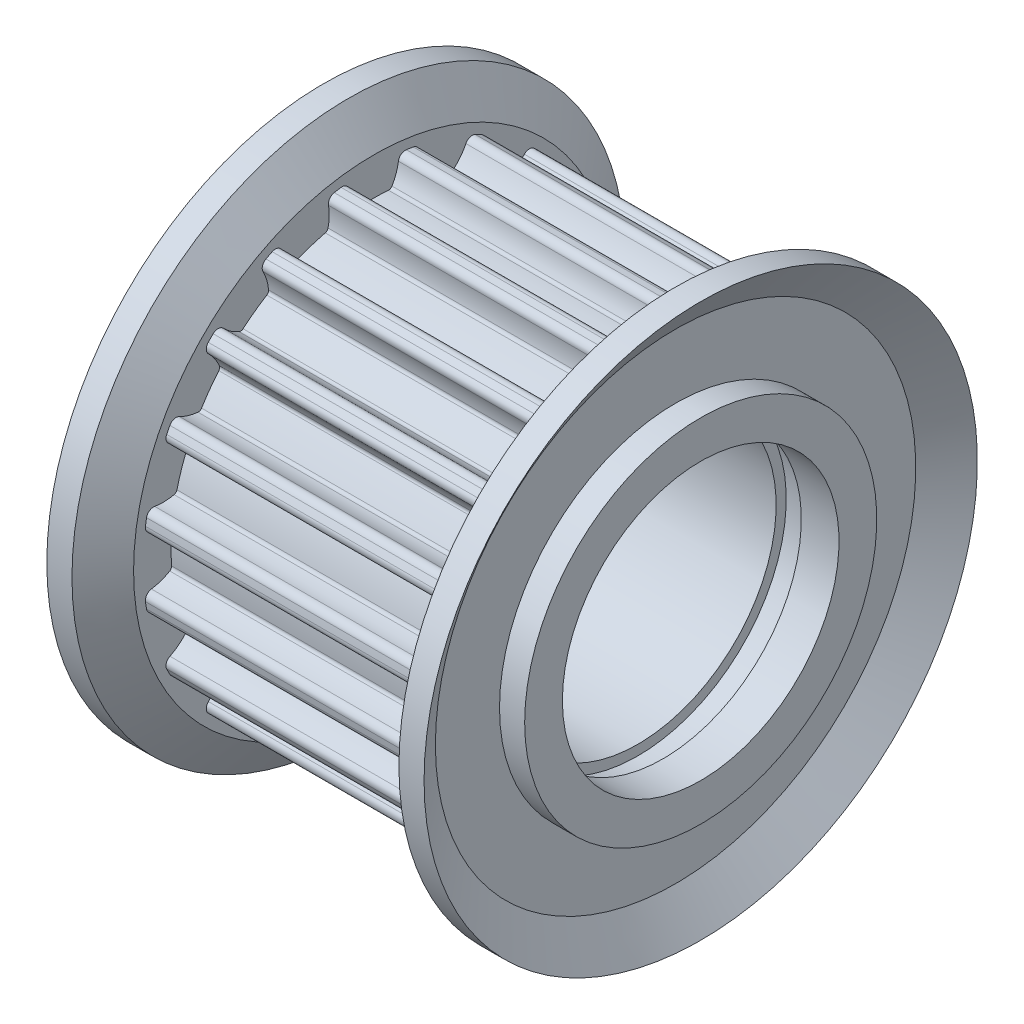
from build123d import *

# Parameters (mm, degrees)
CUT_EXTRUDE1_DEPTH  = 11
CUT_EXTRUDE2_DEPTH  = 11
CUT_EXTRUDE3_DEPTH  = 11
CUT_EXTRUDE4_DEPTH  = 11
CUT_EXTRUDE5_DEPTH  = 11
CUT_EXTRUDE6_DEPTH  = 11
CUT_EXTRUDE7_DEPTH  = 11
CUT_EXTRUDE8_DEPTH  = 11
CUT_EXTRUDE9_DEPTH  = 11
CUT_EXTRUDE10_DEPTH = 11
CUT_EXTRUDE11_DEPTH = 11
CUT_EXTRUDE12_DEPTH = 11
CUT_EXTRUDE13_DEPTH = 11
CUT_EXTRUDE14_DEPTH = 11
CUT_EXTRUDE15_DEPTH = 11
CUT_EXTRUDE16_DEPTH = 11
CUT_EXTRUDE17_DEPTH = 11
CUT_EXTRUDE18_DEPTH = 11
CUT_EXTRUDE19_DEPTH = 11
CUT_EXTRUDE20_DEPTH = 11
SKETCH23_R          = 5
CUT_EXTRUDE21_DEPTH = 16
SKETCH24_R          = 0.75
CUT_EXTRUDE22_DEPTH = 12


with BuildPart() as part:
    # Sketch1 → Revolve1 (revolve)
    with BuildSketch(Plane.XY):
        Polygon((-7.5, 4.5), (-5, 4.5), (-5, 5.5), (5, 5.5), (5, 5.9), (6, 5.9), (6, 5.5), (7.5, 5.5), (7.5, 7), (6.5, 7), (6.5, 9.55), (7.5, 11), (6.5, 11), (5.5, 9.55), (5.5, 9.17), (-5.5, 9.17), (-5.5, 9.55), (-6.5, 11), (-7.5, 11), (-6.5, 9.55), (-6.5, 7), (-7.5, 7), align=None)
    revolve(axis=Axis((20, 0, 0), (-1, 0, 0)))

    # Sketch2 → Cut-Extrude1 (cut)
    with BuildSketch(Plane(origin=(5.5, 0, 0), x_dir=(0, 0, -1), z_dir=(1, 0, 0))):
        with BuildLine():
            Line((1.297156606, 9.077790741), (1.297156606, 9.846928899))
            ThreePointArc((1.297156606, 9.846928899), (0, 9.932), (-1.297156606, 9.846928899))
            Line((-1.297156606, 9.846928899), (-1.297156606, 9.077790741))
            ThreePointArc((-1.297156606, 9.077790741), (-1.089477901, 9.024553121), (-0.980336508, 8.840018991))
            ThreePointArc((-0.980336508, 8.840018991), (-0.888349543, 8.463379284), (-0.724554349, 8.111967552))
            ThreePointArc((-0.724554349, 8.111967552), (-0.664988681, 8.055456464), (-0.584594729, 8.03877161))
            ThreePointArc((-0.584594729, 8.03877161), (7.9e-08, 8.06), (0.584594886, 8.038771599))
            ThreePointArc((0.584594886, 8.038771599), (0.664988748, 8.055456499), (0.724554346, 8.111967546))
            ThreePointArc((0.724554346, 8.111967546), (0.888349546, 8.463379292), (0.980336511, 8.840019016))
            ThreePointArc((0.980336511, 8.840019016), (1.089477911, 9.024553128), (1.297156606, 9.077790741))
        make_face()
    extrude(amount=-CUT_EXTRUDE1_DEPTH, mode=Mode.SUBTRACT)

    # Sketch3 → Cut-Extrude2 (cut)
    with BuildSketch(Plane(origin=(5.5, 0, 0), x_dir=(0, 0, -1), z_dir=(1, 0, 0))):
        with BuildLine():
            Line((4.038860853, 8.232648602), (4.276537615, 8.964142459))
            ThreePointArc((4.276537615, 8.964142459), (3.069156788, 9.44589332), (1.809199129, 9.76582933))
            Line((1.809199129, 9.76582933), (1.571522367, 9.034335474))
            ThreePointArc((1.571522367, 9.034335474), (1.752585224, 8.919527239), (1.799360675, 8.710298307))
            ThreePointArc((1.799360675, 8.710298307), (1.770457407, 8.323667124), (1.817643696, 7.938839208))
            ThreePointArc((1.817643696, 7.938839208), (1.856831127, 7.866687166), (1.928134415, 7.825975829))
            ThreePointArc((1.928134415, 7.825975829), (2.49067705, 7.665515497), (3.040099814, 7.464676358))
            ThreePointArc((3.040099814, 7.464676358), (3.121714837, 7.455701571), (3.195827961, 7.491039989))
            ThreePointArc((3.195827961, 7.491039989), (3.460198655, 7.774636919), (3.664071533, 8.104417047))
            ThreePointArc((3.664071533, 8.104417047), (3.82489535, 8.24619287), (4.038860853, 8.232648602))
        make_face()
    extrude(amount=-CUT_EXTRUDE2_DEPTH, mode=Mode.SUBTRACT)

    # Sketch4 → Cut-Extrude3 (cut)
    with BuildSketch(Plane(origin=(5.5, 0, 0), x_dir=(0, 0, -1), z_dir=(1, 0, 0))):
        with BuildLine():
            Line((6.38521326, 6.581637458), (6.837301326, 7.203883298))
            ThreePointArc((6.837301326, 7.203883298), (5.837883126, 8.035156788), (4.738457848, 8.728782345))
            Line((4.738457848, 8.728782345), (4.286369782, 8.106536504))
            ThreePointArc((4.286369782, 8.106536504), (4.423093096, 7.941395885), (4.402923898, 7.727952936))
            ThreePointArc((4.402923898, 7.727952936), (4.255959651, 7.369176431), (4.181918112, 6.988601969))
            ThreePointArc((4.181918112, 6.988601969), (4.196891366, 6.907871717), (4.252124329, 6.847119007))
            ThreePointArc((4.252124329, 6.847119007), (4.737549197, 6.520676928), (5.19801859, 6.159886585))
            ThreePointArc((5.19801859, 6.159886585), (5.272865729, 6.126130627), (5.35427167, 6.136837244))
            ThreePointArc((5.35427167, 6.136837244), (5.693339412, 6.324858916), (5.989141705, 6.575498271))
            ThreePointArc((5.989141705, 6.575498271), (6.185905382, 6.660637799), (6.38521326, 6.581637458))
        make_face()
    extrude(amount=-CUT_EXTRUDE3_DEPTH, mode=Mode.SUBTRACT)

    # Sketch5 → Cut-Extrude4 (cut)
    with BuildSketch(Plane(origin=(5.5, 0, 0), x_dir=(0, 0, -1), z_dir=(1, 0, 0))):
        with BuildLine():
            Line((8.106536504, 4.286369782), (8.728782345, 4.738457848))
            ThreePointArc((8.728782345, 4.738457848), (8.035156788, 5.837883126), (7.203883298, 6.837301326))
            Line((7.203883298, 6.837301326), (6.581637458, 6.38521326))
            ThreePointArc((6.581637458, 6.38521326), (6.660637799, 6.18590537), (6.575498253, 5.989141688))
            ThreePointArc((6.575498253, 5.989141688), (6.324858911, 5.693339405), (6.136837247, 5.354271676))
            ThreePointArc((6.136837247, 5.354271676), (6.126130638, 5.272865654), (6.159886687, 5.198018469))
            ThreePointArc((6.159886687, 5.198018469), (6.520677021, 4.73754907), (6.84711909, 4.252124195))
            ThreePointArc((6.84711909, 4.252124195), (6.907871784, 4.196891333), (6.988601962, 4.181918112))
            ThreePointArc((6.988601962, 4.181918112), (7.369176439, 4.255959653), (7.727952958, 4.40292391))
            ThreePointArc((7.727952958, 4.40292391), (7.941395896, 4.423093092), (8.106536504, 4.286369782))
        make_face()
    extrude(amount=-CUT_EXTRUDE4_DEPTH, mode=Mode.SUBTRACT)

    # Sketch6 → Cut-Extrude5 (cut)
    with BuildSketch(Plane(origin=(5.5, 0, 0), x_dir=(0, 0, -1), z_dir=(1, 0, 0))):
        with BuildLine():
            Line((9.034335474, 1.571522367), (9.76582933, 1.809199129))
            ThreePointArc((9.76582933, 1.809199129), (9.44589332, 3.069156788), (8.964142459, 4.276537615))
            Line((8.964142459, 4.276537615), (8.232648602, 4.038860853))
            ThreePointArc((8.232648602, 4.038860853), (8.246192866, 3.824895338), (8.104417025, 3.664071523))
            ThreePointArc((8.104417025, 3.664071523), (7.774636913, 3.46019865), (7.491039993, 3.195827967))
            ThreePointArc((7.491039993, 3.195827967), (7.455701559, 3.121714763), (7.464676417, 3.040099668))
            ThreePointArc((7.464676417, 3.040099668), (7.665515546, 2.4906769), (7.825975867, 1.928134262))
            ThreePointArc((7.825975867, 1.928134262), (7.866687219, 1.856831074), (7.938839201, 1.817643698))
            ThreePointArc((7.938839201, 1.817643698), (8.323667132, 1.770457407), (8.710298331, 1.79936068))
            ThreePointArc((8.710298331, 1.79936068), (8.919527249, 1.752585217), (9.034335474, 1.571522367))
        make_face()
    extrude(amount=-CUT_EXTRUDE5_DEPTH, mode=Mode.SUBTRACT)

    # Sketch7 → Cut-Extrude6 (cut)
    with BuildSketch(Plane(origin=(5.5, 0, 0), x_dir=(0, 0, -1), z_dir=(1, 0, 0))):
        with BuildLine():
            Line((9.077790741, -1.297156606), (9.846928899, -1.297156606))
            ThreePointArc((9.846928899, -1.297156606), (9.932, 0), (9.846928899, 1.297156606))
            Line((9.846928899, 1.297156606), (9.077790741, 1.297156606))
            ThreePointArc((9.077790741, 1.297156606), (9.024553121, 1.089477901), (8.840018991, 0.980336508))
            ThreePointArc((8.840018991, 0.980336508), (8.463379284, 0.888349543), (8.111967552, 0.724554349))
            ThreePointArc((8.111967552, 0.724554349), (8.055456464, 0.664988681), (8.03877161, 0.584594729))
            ThreePointArc((8.03877161, 0.584594729), (8.06, -7.9e-08), (8.038771599, -0.584594886))
            ThreePointArc((8.038771599, -0.584594886), (8.055456499, -0.664988748), (8.111967546, -0.724554346))
            ThreePointArc((8.111967546, -0.724554346), (8.463379292, -0.888349546), (8.840019016, -0.980336511))
            ThreePointArc((8.840019016, -0.980336511), (9.024553128, -1.089477911), (9.077790741, -1.297156606))
        make_face()
    extrude(amount=-CUT_EXTRUDE6_DEPTH, mode=Mode.SUBTRACT)

    # Sketch8 → Cut-Extrude7 (cut)
    with BuildSketch(Plane(origin=(5.5, 0, 0), x_dir=(0, 0, -1), z_dir=(1, 0, 0))):
        with BuildLine():
            Line((8.232648602, -4.038860853), (8.964142459, -4.276537615))
            ThreePointArc((8.964142459, -4.276537615), (9.44589332, -3.069156788), (9.76582933, -1.809199129))
            Line((9.76582933, -1.809199129), (9.034335474, -1.571522367))
            ThreePointArc((9.034335474, -1.571522367), (8.919527239, -1.752585224), (8.710298307, -1.799360675))
            ThreePointArc((8.710298307, -1.799360675), (8.323667124, -1.770457407), (7.938839208, -1.817643696))
            ThreePointArc((7.938839208, -1.817643696), (7.866687166, -1.856831127), (7.825975829, -1.928134415))
            ThreePointArc((7.825975829, -1.928134415), (7.665515497, -2.49067705), (7.464676358, -3.040099814))
            ThreePointArc((7.464676358, -3.040099814), (7.455701571, -3.121714837), (7.491039989, -3.195827961))
            ThreePointArc((7.491039989, -3.195827961), (7.774636919, -3.460198655), (8.104417047, -3.664071533))
            ThreePointArc((8.104417047, -3.664071533), (8.24619287, -3.82489535), (8.232648602, -4.038860853))
        make_face()
    extrude(amount=-CUT_EXTRUDE7_DEPTH, mode=Mode.SUBTRACT)

    # Sketch9 → Cut-Extrude8 (cut)
    with BuildSketch(Plane(origin=(5.5, 0, 0), x_dir=(0, 0, -1), z_dir=(1, 0, 0))):
        with BuildLine():
            Line((6.581637458, -6.38521326), (7.203883298, -6.837301326))
            ThreePointArc((7.203883298, -6.837301326), (8.035156788, -5.837883126), (8.728782345, -4.738457848))
            Line((8.728782345, -4.738457848), (8.106536504, -4.286369782))
            ThreePointArc((8.106536504, -4.286369782), (7.941395885, -4.423093096), (7.727952936, -4.402923898))
            ThreePointArc((7.727952936, -4.402923898), (7.369176431, -4.255959651), (6.988601969, -4.181918112))
            ThreePointArc((6.988601969, -4.181918112), (6.907871717, -4.196891366), (6.847119007, -4.252124329))
            ThreePointArc((6.847119007, -4.252124329), (6.520676928, -4.737549197), (6.159886585, -5.19801859))
            ThreePointArc((6.159886585, -5.19801859), (6.126130627, -5.272865729), (6.136837244, -5.35427167))
            ThreePointArc((6.136837244, -5.35427167), (6.324858916, -5.693339412), (6.575498271, -5.989141705))
            ThreePointArc((6.575498271, -5.989141705), (6.660637799, -6.185905382), (6.581637458, -6.38521326))
        make_face()
    extrude(amount=-CUT_EXTRUDE8_DEPTH, mode=Mode.SUBTRACT)

    # Sketch10 → Cut-Extrude9 (cut)
    with BuildSketch(Plane(origin=(5.5, 0, 0), x_dir=(0, 0, -1), z_dir=(1, 0, 0))):
        with BuildLine():
            Line((4.286369782, -8.106536504), (4.738457848, -8.728782345))
            ThreePointArc((4.738457848, -8.728782345), (5.837883126, -8.035156788), (6.837301326, -7.203883298))
            Line((6.837301326, -7.203883298), (6.38521326, -6.581637458))
            ThreePointArc((6.38521326, -6.581637458), (6.18590537, -6.660637799), (5.989141688, -6.575498253))
            ThreePointArc((5.989141688, -6.575498253), (5.693339405, -6.324858911), (5.354271676, -6.136837247))
            ThreePointArc((5.354271676, -6.136837247), (5.272865654, -6.126130638), (5.198018469, -6.159886687))
            ThreePointArc((5.198018469, -6.159886687), (4.73754907, -6.520677021), (4.252124195, -6.84711909))
            ThreePointArc((4.252124195, -6.84711909), (4.196891333, -6.907871784), (4.181918112, -6.988601962))
            ThreePointArc((4.181918112, -6.988601962), (4.255959653, -7.369176439), (4.40292391, -7.727952958))
            ThreePointArc((4.40292391, -7.727952958), (4.423093092, -7.941395896), (4.286369782, -8.106536504))
        make_face()
    extrude(amount=-CUT_EXTRUDE9_DEPTH, mode=Mode.SUBTRACT)

    # Sketch11 → Cut-Extrude10 (cut)
    with BuildSketch(Plane(origin=(5.5, 0, 0), x_dir=(0, 0, -1), z_dir=(1, 0, 0))):
        with BuildLine():
            Line((1.571522367, -9.034335474), (1.809199129, -9.76582933))
            ThreePointArc((1.809199129, -9.76582933), (3.069156788, -9.44589332), (4.276537615, -8.964142459))
            Line((4.276537615, -8.964142459), (4.038860853, -8.232648602))
            ThreePointArc((4.038860853, -8.232648602), (3.824895338, -8.246192866), (3.664071523, -8.104417025))
            ThreePointArc((3.664071523, -8.104417025), (3.46019865, -7.774636913), (3.195827967, -7.491039993))
            ThreePointArc((3.195827967, -7.491039993), (3.121714763, -7.455701559), (3.040099668, -7.464676417))
            ThreePointArc((3.040099668, -7.464676417), (2.4906769, -7.665515546), (1.928134262, -7.825975867))
            ThreePointArc((1.928134262, -7.825975867), (1.856831074, -7.866687219), (1.817643698, -7.938839201))
            ThreePointArc((1.817643698, -7.938839201), (1.770457407, -8.323667132), (1.79936068, -8.710298331))
            ThreePointArc((1.79936068, -8.710298331), (1.752585217, -8.919527249), (1.571522367, -9.034335474))
        make_face()
    extrude(amount=-CUT_EXTRUDE10_DEPTH, mode=Mode.SUBTRACT)

    # Sketch12 → Cut-Extrude11 (cut)
    with BuildSketch(Plane(origin=(5.5, 0, 0), x_dir=(0, 0, -1), z_dir=(1, 0, 0))):
        with BuildLine():
            Line((-1.297156606, -9.077790741), (-1.297156606, -9.846928899))
            ThreePointArc((-1.297156606, -9.846928899), (0, -9.932), (1.297156606, -9.846928899))
            Line((1.297156606, -9.846928899), (1.297156606, -9.077790741))
            ThreePointArc((1.297156606, -9.077790741), (1.089477901, -9.024553121), (0.980336508, -8.840018991))
            ThreePointArc((0.980336508, -8.840018991), (0.888349543, -8.463379284), (0.724554349, -8.111967552))
            ThreePointArc((0.724554349, -8.111967552), (0.664988681, -8.055456464), (0.584594729, -8.03877161))
            ThreePointArc((0.584594729, -8.03877161), (-7.9e-08, -8.06), (-0.584594886, -8.038771599))
            ThreePointArc((-0.584594886, -8.038771599), (-0.664988748, -8.055456499), (-0.724554346, -8.111967546))
            ThreePointArc((-0.724554346, -8.111967546), (-0.888349546, -8.463379292), (-0.980336511, -8.840019016))
            ThreePointArc((-0.980336511, -8.840019016), (-1.089477911, -9.024553128), (-1.297156606, -9.077790741))
        make_face()
    extrude(amount=-CUT_EXTRUDE11_DEPTH, mode=Mode.SUBTRACT)

    # Sketch13 → Cut-Extrude12 (cut)
    with BuildSketch(Plane(origin=(5.5, 0, 0), x_dir=(0, 0, -1), z_dir=(1, 0, 0))):
        with BuildLine():
            Line((-4.038860853, -8.232648602), (-4.276537615, -8.964142459))
            ThreePointArc((-4.276537615, -8.964142459), (-3.069156788, -9.44589332), (-1.809199129, -9.76582933))
            Line((-1.809199129, -9.76582933), (-1.571522367, -9.034335474))
            ThreePointArc((-1.571522367, -9.034335474), (-1.752585224, -8.919527239), (-1.799360675, -8.710298307))
            ThreePointArc((-1.799360675, -8.710298307), (-1.770457407, -8.323667124), (-1.817643696, -7.938839208))
            ThreePointArc((-1.817643696, -7.938839208), (-1.856831127, -7.866687166), (-1.928134415, -7.825975829))
            ThreePointArc((-1.928134415, -7.825975829), (-2.49067705, -7.665515497), (-3.040099814, -7.464676358))
            ThreePointArc((-3.040099814, -7.464676358), (-3.121714837, -7.455701571), (-3.195827961, -7.491039989))
            ThreePointArc((-3.195827961, -7.491039989), (-3.460198655, -7.774636919), (-3.664071533, -8.104417047))
            ThreePointArc((-3.664071533, -8.104417047), (-3.82489535, -8.24619287), (-4.038860853, -8.232648602))
        make_face()
    extrude(amount=-CUT_EXTRUDE12_DEPTH, mode=Mode.SUBTRACT)

    # Sketch14 → Cut-Extrude13 (cut)
    with BuildSketch(Plane(origin=(5.5, 0, 0), x_dir=(0, 0, -1), z_dir=(1, 0, 0))):
        with BuildLine():
            Line((-6.38521326, -6.581637458), (-6.837301326, -7.203883298))
            ThreePointArc((-6.837301326, -7.203883298), (-5.837883126, -8.035156788), (-4.738457848, -8.728782345))
            Line((-4.738457848, -8.728782345), (-4.286369782, -8.106536504))
            ThreePointArc((-4.286369782, -8.106536504), (-4.423093096, -7.941395885), (-4.402923898, -7.727952936))
            ThreePointArc((-4.402923898, -7.727952936), (-4.255959651, -7.369176431), (-4.181918112, -6.988601969))
            ThreePointArc((-4.181918112, -6.988601969), (-4.196891366, -6.907871717), (-4.252124329, -6.847119007))
            ThreePointArc((-4.252124329, -6.847119007), (-4.737549197, -6.520676928), (-5.19801859, -6.159886585))
            ThreePointArc((-5.19801859, -6.159886585), (-5.272865729, -6.126130627), (-5.35427167, -6.136837244))
            ThreePointArc((-5.35427167, -6.136837244), (-5.693339412, -6.324858916), (-5.989141705, -6.575498271))
            ThreePointArc((-5.989141705, -6.575498271), (-6.185905382, -6.660637799), (-6.38521326, -6.581637458))
        make_face()
    extrude(amount=-CUT_EXTRUDE13_DEPTH, mode=Mode.SUBTRACT)

    # Sketch15 → Cut-Extrude14 (cut)
    with BuildSketch(Plane(origin=(5.5, 0, 0), x_dir=(0, 0, -1), z_dir=(1, 0, 0))):
        with BuildLine():
            Line((-8.106536504, -4.286369782), (-8.728782345, -4.738457848))
            ThreePointArc((-8.728782345, -4.738457848), (-8.035156788, -5.837883126), (-7.203883298, -6.837301326))
            Line((-7.203883298, -6.837301326), (-6.581637458, -6.38521326))
            ThreePointArc((-6.581637458, -6.38521326), (-6.660637799, -6.18590537), (-6.575498253, -5.989141688))
            ThreePointArc((-6.575498253, -5.989141688), (-6.324858911, -5.693339405), (-6.136837247, -5.354271676))
            ThreePointArc((-6.136837247, -5.354271676), (-6.126130638, -5.272865654), (-6.159886687, -5.198018469))
            ThreePointArc((-6.159886687, -5.198018469), (-6.520677021, -4.73754907), (-6.84711909, -4.252124195))
            ThreePointArc((-6.84711909, -4.252124195), (-6.907871784, -4.196891333), (-6.988601962, -4.181918112))
            ThreePointArc((-6.988601962, -4.181918112), (-7.369176439, -4.255959653), (-7.727952958, -4.40292391))
            ThreePointArc((-7.727952958, -4.40292391), (-7.941395896, -4.423093092), (-8.106536504, -4.286369782))
        make_face()
    extrude(amount=-CUT_EXTRUDE14_DEPTH, mode=Mode.SUBTRACT)

    # Sketch16 → Cut-Extrude15 (cut)
    with BuildSketch(Plane(origin=(5.5, 0, 0), x_dir=(0, 0, -1), z_dir=(1, 0, 0))):
        with BuildLine():
            Line((-9.034335474, -1.571522367), (-9.76582933, -1.809199129))
            ThreePointArc((-9.76582933, -1.809199129), (-9.44589332, -3.069156788), (-8.964142459, -4.276537615))
            Line((-8.964142459, -4.276537615), (-8.232648602, -4.038860853))
            ThreePointArc((-8.232648602, -4.038860853), (-8.246192866, -3.824895338), (-8.104417025, -3.664071523))
            ThreePointArc((-8.104417025, -3.664071523), (-7.774636913, -3.46019865), (-7.491039993, -3.195827967))
            ThreePointArc((-7.491039993, -3.195827967), (-7.455701559, -3.121714763), (-7.464676417, -3.040099668))
            ThreePointArc((-7.464676417, -3.040099668), (-7.665515546, -2.4906769), (-7.825975867, -1.928134262))
            ThreePointArc((-7.825975867, -1.928134262), (-7.866687219, -1.856831074), (-7.938839201, -1.817643698))
            ThreePointArc((-7.938839201, -1.817643698), (-8.323667132, -1.770457407), (-8.710298331, -1.79936068))
            ThreePointArc((-8.710298331, -1.79936068), (-8.919527249, -1.752585217), (-9.034335474, -1.571522367))
        make_face()
    extrude(amount=-CUT_EXTRUDE15_DEPTH, mode=Mode.SUBTRACT)

    # Sketch17 → Cut-Extrude16 (cut)
    with BuildSketch(Plane(origin=(5.5, 0, 0), x_dir=(0, 0, -1), z_dir=(1, 0, 0))):
        with BuildLine():
            Line((-9.077790741, 1.297156606), (-9.846928899, 1.297156606))
            ThreePointArc((-9.846928899, 1.297156606), (-9.932, 0), (-9.846928899, -1.297156606))
            Line((-9.846928899, -1.297156606), (-9.077790741, -1.297156606))
            ThreePointArc((-9.077790741, -1.297156606), (-9.024553121, -1.089477901), (-8.840018991, -0.980336508))
            ThreePointArc((-8.840018991, -0.980336508), (-8.463379284, -0.888349543), (-8.111967552, -0.724554349))
            ThreePointArc((-8.111967552, -0.724554349), (-8.055456464, -0.664988681), (-8.03877161, -0.584594729))
            ThreePointArc((-8.03877161, -0.584594729), (-8.06, 7.9e-08), (-8.038771599, 0.584594886))
            ThreePointArc((-8.038771599, 0.584594886), (-8.055456499, 0.664988748), (-8.111967546, 0.724554346))
            ThreePointArc((-8.111967546, 0.724554346), (-8.463379292, 0.888349546), (-8.840019016, 0.980336511))
            ThreePointArc((-8.840019016, 0.980336511), (-9.024553128, 1.089477911), (-9.077790741, 1.297156606))
        make_face()
    extrude(amount=-CUT_EXTRUDE16_DEPTH, mode=Mode.SUBTRACT)

    # Sketch18 → Cut-Extrude17 (cut)
    with BuildSketch(Plane(origin=(5.5, 0, 0), x_dir=(0, 0, -1), z_dir=(1, 0, 0))):
        with BuildLine():
            Line((-8.232648602, 4.038860853), (-8.964142459, 4.276537615))
            ThreePointArc((-8.964142459, 4.276537615), (-9.44589332, 3.069156788), (-9.76582933, 1.809199129))
            Line((-9.76582933, 1.809199129), (-9.034335474, 1.571522367))
            ThreePointArc((-9.034335474, 1.571522367), (-8.919527239, 1.752585224), (-8.710298307, 1.799360675))
            ThreePointArc((-8.710298307, 1.799360675), (-8.323667124, 1.770457407), (-7.938839208, 1.817643696))
            ThreePointArc((-7.938839208, 1.817643696), (-7.866687166, 1.856831127), (-7.825975829, 1.928134415))
            ThreePointArc((-7.825975829, 1.928134415), (-7.665515497, 2.49067705), (-7.464676358, 3.040099814))
            ThreePointArc((-7.464676358, 3.040099814), (-7.455701571, 3.121714837), (-7.491039989, 3.195827961))
            ThreePointArc((-7.491039989, 3.195827961), (-7.774636919, 3.460198655), (-8.104417047, 3.664071533))
            ThreePointArc((-8.104417047, 3.664071533), (-8.24619287, 3.82489535), (-8.232648602, 4.038860853))
        make_face()
    extrude(amount=-CUT_EXTRUDE17_DEPTH, mode=Mode.SUBTRACT)

    # Sketch19 → Cut-Extrude18 (cut)
    with BuildSketch(Plane(origin=(5.5, 0, 0), x_dir=(0, 0, -1), z_dir=(1, 0, 0))):
        with BuildLine():
            Line((-6.581637458, 6.38521326), (-7.203883298, 6.837301326))
            ThreePointArc((-7.203883298, 6.837301326), (-8.035156788, 5.837883126), (-8.728782345, 4.738457848))
            Line((-8.728782345, 4.738457848), (-8.106536504, 4.286369782))
            ThreePointArc((-8.106536504, 4.286369782), (-7.941395885, 4.423093096), (-7.727952936, 4.402923898))
            ThreePointArc((-7.727952936, 4.402923898), (-7.369176431, 4.255959651), (-6.988601969, 4.181918112))
            ThreePointArc((-6.988601969, 4.181918112), (-6.907871717, 4.196891366), (-6.847119007, 4.252124329))
            ThreePointArc((-6.847119007, 4.252124329), (-6.520676928, 4.737549197), (-6.159886585, 5.19801859))
            ThreePointArc((-6.159886585, 5.19801859), (-6.126130627, 5.272865729), (-6.136837244, 5.35427167))
            ThreePointArc((-6.136837244, 5.35427167), (-6.324858916, 5.693339412), (-6.575498271, 5.989141705))
            ThreePointArc((-6.575498271, 5.989141705), (-6.660637799, 6.185905382), (-6.581637458, 6.38521326))
        make_face()
    extrude(amount=-CUT_EXTRUDE18_DEPTH, mode=Mode.SUBTRACT)

    # Sketch20 → Cut-Extrude19 (cut)
    with BuildSketch(Plane(origin=(5.5, 0, 0), x_dir=(0, 0, -1), z_dir=(1, 0, 0))):
        with BuildLine():
            Line((-4.286369782, 8.106536504), (-4.738457848, 8.728782345))
            ThreePointArc((-4.738457848, 8.728782345), (-5.837883126, 8.035156788), (-6.837301326, 7.203883298))
            Line((-6.837301326, 7.203883298), (-6.38521326, 6.581637458))
            ThreePointArc((-6.38521326, 6.581637458), (-6.18590537, 6.660637799), (-5.989141688, 6.575498253))
            ThreePointArc((-5.989141688, 6.575498253), (-5.693339405, 6.324858911), (-5.354271676, 6.136837247))
            ThreePointArc((-5.354271676, 6.136837247), (-5.272865654, 6.126130638), (-5.198018469, 6.159886687))
            ThreePointArc((-5.198018469, 6.159886687), (-4.73754907, 6.520677021), (-4.252124195, 6.84711909))
            ThreePointArc((-4.252124195, 6.84711909), (-4.196891333, 6.907871784), (-4.181918112, 6.988601962))
            ThreePointArc((-4.181918112, 6.988601962), (-4.255959653, 7.369176439), (-4.40292391, 7.727952958))
            ThreePointArc((-4.40292391, 7.727952958), (-4.423093092, 7.941395896), (-4.286369782, 8.106536504))
        make_face()
    extrude(amount=-CUT_EXTRUDE19_DEPTH, mode=Mode.SUBTRACT)

    # Sketch21 → Cut-Extrude20 (cut)
    with BuildSketch(Plane(origin=(5.5, 0, 0), x_dir=(0, 0, -1), z_dir=(1, 0, 0))):
        with BuildLine():
            Line((-1.571522367, 9.034335474), (-1.809199129, 9.76582933))
            ThreePointArc((-1.809199129, 9.76582933), (-3.069156788, 9.44589332), (-4.276537615, 8.964142459))
            Line((-4.276537615, 8.964142459), (-4.038860853, 8.232648602))
            ThreePointArc((-4.038860853, 8.232648602), (-3.824895338, 8.246192866), (-3.664071523, 8.104417025))
            ThreePointArc((-3.664071523, 8.104417025), (-3.46019865, 7.774636913), (-3.195827967, 7.491039993))
            ThreePointArc((-3.195827967, 7.491039993), (-3.121714763, 7.455701559), (-3.040099668, 7.464676417))
            ThreePointArc((-3.040099668, 7.464676417), (-2.4906769, 7.665515546), (-1.928134262, 7.825975867))
            ThreePointArc((-1.928134262, 7.825975867), (-1.856831074, 7.866687219), (-1.817643698, 7.938839201))
            ThreePointArc((-1.817643698, 7.938839201), (-1.770457407, 8.323667132), (-1.79936068, 8.710298331))
            ThreePointArc((-1.79936068, 8.710298331), (-1.752585217, 8.919527249), (-1.571522367, 9.034335474))
        make_face()
    extrude(amount=-CUT_EXTRUDE20_DEPTH, mode=Mode.SUBTRACT)

    # Sketch23 → Cut-Extrude21 (cut, through all)
    with BuildSketch(Plane.ZY.offset(7.5)):
        Circle(SKETCH23_R)
    extrude(amount=-CUT_EXTRUDE21_DEPTH, mode=Mode.SUBTRACT)

    # Sketch24 → Cut-Extrude22 (cut, through all)
    with BuildSketch(Plane(origin=(0, 0, 0), x_dir=(1, 0, 0), z_dir=(0, 1, 0))):
        Circle(SKETCH24_R)
    extrude(amount=-CUT_EXTRUDE22_DEPTH, mode=Mode.SUBTRACT)


solid = part.part
